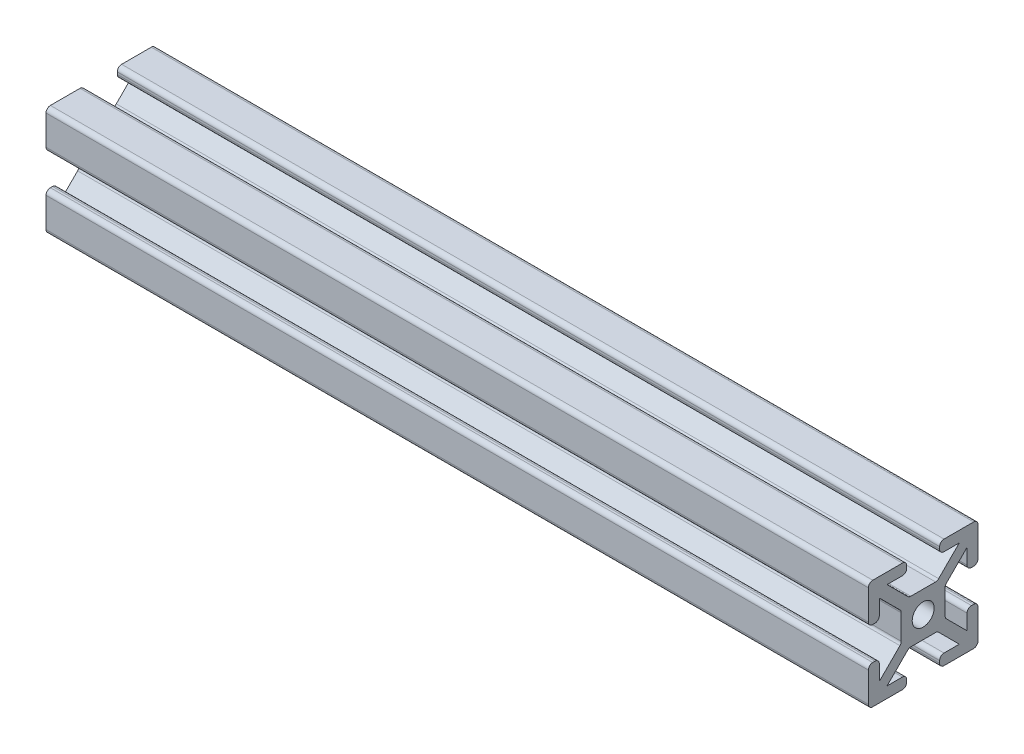
from build123d import *

# Parameters (mm, degrees)
SKETCH1_R           = 2
PROFILE_4X4_1_DEPTH = 150


with BuildPart() as part:
    # Sketch1 → Profile 4X4(1) (new body)
    with BuildSketch(Plane.YZ.offset(-67.810457516)):
        with BuildLine():
            Line((-3, 9.2), (-3, 8.8))
            ThreePointArc((-3, 8.8), (-3.234314575, 8.234314575), (-3.8, 8))
            Line((-3.8, 8), (-6.585786438, 8))
            Line((-6.585786438, 8), (-2.820101013, 4.234314575))
            ThreePointArc((-2.820101013, 4.234314575), (-2.560562334, 4.060896374), (-2.254415588, 4))
            Line((-2.254415588, 4), (2.254415588, 4))
            ThreePointArc((2.254415588, 4), (2.560562334, 4.060896374), (2.820101013, 4.234314575))
            Line((2.820101013, 4.234314575), (6.585786438, 8))
            Line((6.585786438, 8), (3.8, 8))
            ThreePointArc((3.8, 8), (3.234314575, 8.234314575), (3, 8.8))
            Line((3, 8.8), (3, 9.2))
            ThreePointArc((3, 9.2), (3.234314575, 9.765685425), (3.8, 10))
            Line((3.8, 10), (9.2, 10))
            ThreePointArc((9.2, 10), (9.765685425, 9.765685425), (10, 9.2))
            Line((10, 9.2), (10, 3.8))
            ThreePointArc((10, 3.8), (9.765685425, 3.234314575), (9.2, 3))
            Line((9.2, 3), (8.8, 3))
            ThreePointArc((8.8, 3), (8.234314575, 3.234314575), (8, 3.8))
            Line((8, 3.8), (8, 6.585786438))
            Line((8, 6.585786438), (4.234314575, 2.820101013))
            ThreePointArc((4.234314575, 2.820101013), (4.060896374, 2.560562334), (4, 2.254415588))
            Line((4, 2.254415588), (4, -2.254415588))
            ThreePointArc((4, -2.254415588), (4.060896374, -2.560562334), (4.234314575, -2.820101013))
            Line((4.234314575, -2.820101013), (8, -6.585786438))
            Line((8, -6.585786438), (8, -3.8))
            ThreePointArc((8, -3.8), (8.234314575, -3.234314575), (8.8, -3))
            Line((8.8, -3), (9.2, -3))
            ThreePointArc((9.2, -3), (9.765685425, -3.234314575), (10, -3.8))
            Line((10, -3.8), (10, -9.2))
            ThreePointArc((10, -9.2), (9.765685425, -9.765685425), (9.2, -10))
            Line((9.2, -10), (3.8, -10))
            ThreePointArc((3.8, -10), (3.234314575, -9.765685425), (3, -9.2))
            Line((3, -9.2), (3, -8.8))
            ThreePointArc((3, -8.8), (3.234314575, -8.234314575), (3.8, -8))
            Line((3.8, -8), (6.585786438, -8))
            Line((6.585786438, -8), (2.820101013, -4.234314575))
            ThreePointArc((2.820101013, -4.234314575), (2.560562334, -4.060896374), (2.254415588, -4))
            Line((2.254415588, -4), (-2.254415588, -4))
            ThreePointArc((-2.254415588, -4), (-2.560562334, -4.060896374), (-2.820101013, -4.234314575))
            Line((-2.820101013, -4.234314575), (-6.585786438, -8))
            Line((-6.585786438, -8), (-3.8, -8))
            ThreePointArc((-3.8, -8), (-3.234314575, -8.234314575), (-3, -8.8))
            Line((-3, -8.8), (-3, -9.2))
            ThreePointArc((-3, -9.2), (-3.234314575, -9.765685425), (-3.8, -10))
            Line((-3.8, -10), (-9.2, -10))
            ThreePointArc((-9.2, -10), (-9.765685425, -9.765685425), (-10, -9.2))
            Line((-10, -9.2), (-10, -3.8))
            ThreePointArc((-10, -3.8), (-9.765685425, -3.234314575), (-9.2, -3))
            Line((-9.2, -3), (-8.8, -3))
            ThreePointArc((-8.8, -3), (-8.234314575, -3.234314575), (-8, -3.8))
            Line((-8, -3.8), (-8, -6.585786438))
            Line((-8, -6.585786438), (-4.234314575, -2.820101013))
            ThreePointArc((-4.234314575, -2.820101013), (-4.060896374, -2.560562334), (-4, -2.254415588))
            Line((-4, -2.254415588), (-4, 2.254415588))
            ThreePointArc((-4, 2.254415588), (-4.060896374, 2.560562334), (-4.234314575, 2.820101013))
            Line((-4.234314575, 2.820101013), (-8, 6.585786438))
            Line((-8, 6.585786438), (-8, 3.8))
            ThreePointArc((-8, 3.8), (-8.234314575, 3.234314575), (-8.8, 3))
            Line((-8.8, 3), (-9.2, 3))
            ThreePointArc((-9.2, 3), (-9.765685425, 3.234314575), (-10, 3.8))
            Line((-10, 3.8), (-10, 9.2))
            ThreePointArc((-10, 9.2), (-9.765685425, 9.765685425), (-9.2, 10))
            Line((-9.2, 10), (-3.8, 10))
            ThreePointArc((-3.8, 10), (-3.234314575, 9.765685425), (-3, 9.2))
        make_face()
        Circle(SKETCH1_R, mode=Mode.SUBTRACT)
    extrude(amount=PROFILE_4X4_1_DEPTH)


solid = part.part
